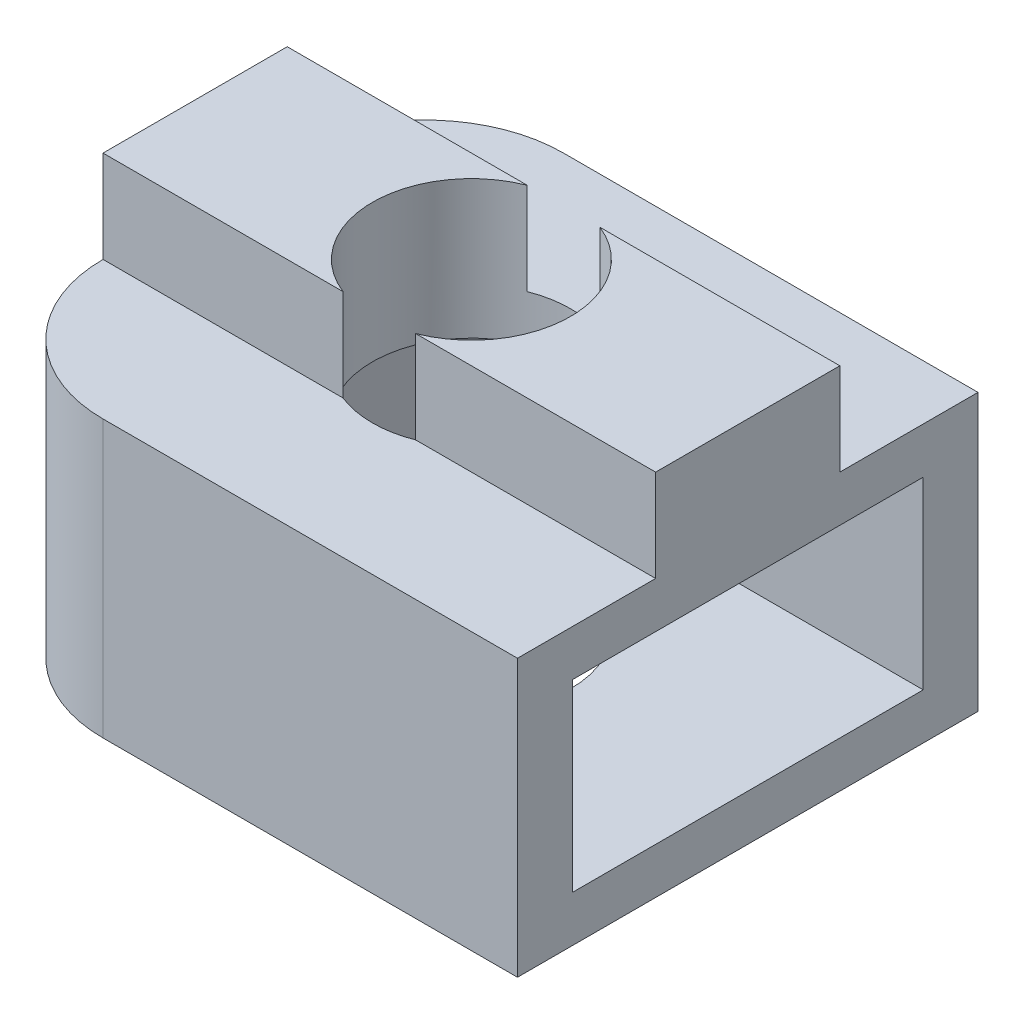
from build123d import *

# Parameters (mm, degrees)
SKETCH1_W               = 12
SKETCH1_H               = 10
BOSS_EXTRUDE1_DEPTH     = 1
BOSS_EXTRUDE2_DEPTH     = 4
SKETCH3_W               = 12
SKETCH3_H               = 10
BOSS_EXTRUDE3_DEPTH     = 1
SKETCH5_W               = 12
SKETCH5_H               = 4
BOSS_EXTRUDE4_DEPTH     = 2
SKETCH4_R               = 2.15
CUT_EXTRUDE1_DEPTH      = 10.848857802
CUT_EXTRUDE1_DEPTH_BACK = 10.848857802
FILLET1_R               = 3


with BuildPart() as part:
    # Sketch1 → Boss-Extrude1 (new body)
    with BuildSketch(Plane(origin=(0, 0, 0), x_dir=(1, 0, 0), z_dir=(0, 1, 0))):
        Rectangle(SKETCH1_W, SKETCH1_H)
    extrude(amount=BOSS_EXTRUDE1_DEPTH)

    # Sketch2 → Boss-Extrude2 (add)
    with BuildSketch(Plane(origin=(0, 1, 0), x_dir=(1, 0, 0), z_dir=(0, 1, 0))):
        Polygon((2.2, -3.810511777), (6, -3.810511777), (6, -5), (-6, -5), (-6, 5), (6, 5), (6, 3.810511777), (2.2, 3.810511777), (-2.2, 3.810511777), (-4.4, 0), (-2.2, -3.810511777), align=None)
    extrude(amount=BOSS_EXTRUDE2_DEPTH)

    # Sketch3 → Boss-Extrude3 (add)
    with BuildSketch(Plane(origin=(0, 5, 0), x_dir=(1, 0, 0), z_dir=(0, 1, 0))):
        Rectangle(SKETCH3_W, SKETCH3_H)
    extrude(amount=BOSS_EXTRUDE3_DEPTH)

    # Sketch5 → Boss-Extrude4 (add)
    with BuildSketch(Plane(origin=(0, 6, 0), x_dir=(1, 0, 0), z_dir=(0, 1, 0))):
        Rectangle(SKETCH5_W, SKETCH5_H)
    extrude(amount=BOSS_EXTRUDE4_DEPTH)

    # Sketch4 → Cut-Extrude1 (cut, two sides)
    with BuildSketch(Plane(origin=(0, 6, 0), x_dir=(1, 0, 0), z_dir=(0, 1, 0))) as cut_extrude1_sk:
        with Locations(Location((0, 0, 0), (0, 0, 270))):
            Circle(SKETCH4_R)
    extrude(amount=CUT_EXTRUDE1_DEPTH, mode=Mode.SUBTRACT)
    extrude(cut_extrude1_sk.sketch, amount=-CUT_EXTRUDE1_DEPTH_BACK, mode=Mode.SUBTRACT)

    # Fillet1
    fillet1_edges = [part.edges().sort_by_distance(p)[0] for p in [
        (-6, 3, 5),
        (-6, 3, -5),
    ]]
    fillet(fillet1_edges, radius=FILLET1_R)


solid = part.part
